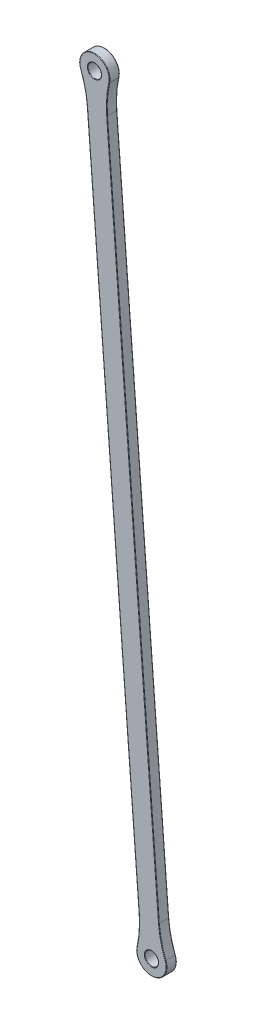
from build123d import *

# Parameters (mm, degrees)
SKETCH1_R           = 2
BOSS_EXTRUDE1_DEPTH = 3
FILLET1_R           = 30
FILLET2_R           = 0.15


with BuildPart() as part:
    # Sketch1 → Boss-Extrude1 (new body)
    with BuildSketch(Plane.XY):
        with BuildLine():
            ThreePointArc((11.251333126, 84.613866333), (14.845502434, 77.013283153), (17.233622255, 85.074536245))
            Line((17.233622255, 85.074536245), (17.491144565, 81.730334956))
            ThreePointArc((17.491144565, 81.730334956), (14.730334956, 78.508855435), (11.508855435, 81.269665044))
            Line((11.508855435, 81.269665044), (11.251333126, 84.613866333))
        make_face()
        with BuildLine():
            Line((0.446357827, 303.075032758), (17.491144565, 81.730334956))
            ThreePointArc((17.491144565, 81.730334956), (14.269665044, 84.491144565), (11.508855435, 81.269665044))
            Line((11.508855435, 81.269665044), (-5.535931303, 302.614362846))
            ThreePointArc((-5.535931303, 302.614362846), (-2.314451782, 299.853553237), (0.446357827, 303.075032758))
        make_face()
        with BuildLine():
            ThreePointArc((-5.535931303, 302.614362846), (-2.775121694, 305.835842367), (0.446357827, 303.075032758))
            Line((0.446357827, 303.075032758), (0.703880137, 299.730831469))
            ThreePointArc((0.703880137, 299.730831469), (-2.890289172, 307.331414649), (-5.278408993, 299.270161557))
            Line((-5.278408993, 299.270161557), (-5.535931303, 302.614362846))
        make_face()
        with BuildLine():
            ThreePointArc((0.446357827, 303.075032758), (-2.314451782, 299.853553237), (-5.535931303, 302.614362846))
            ThreePointArc((-5.535931303, 302.614362846), (-2.775121694, 305.835842367), (0.446357827, 303.075032758))
        make_face()
        with Locations((-2.544786738, 302.844697802)):
            Circle(SKETCH1_R, mode=Mode.SUBTRACT)
        with BuildLine():
            ThreePointArc((11.508855435, 81.269665044), (14.730334956, 78.508855435), (17.491144565, 81.730334956))
            ThreePointArc((17.491144565, 81.730334956), (14.269665044, 84.491144565), (11.508855435, 81.269665044))
        make_face()
        with Locations((14.5, 81.5)):
            Circle(SKETCH1_R, mode=Mode.SUBTRACT)
    extrude(amount=-BOSS_EXTRUDE1_DEPTH)

    # Fillet1
    fillet1_edges = [part.edges().sort_by_distance(p)[0] for p in [
        (17.233622255, 85.074536245, -1.5),
        (11.251333126, 84.613866333, -1.5),
        (-5.278408993, 299.270161557, -1.5),
        (0.703880137, 299.730831469, -1.5),
    ]]
    fillet(fillet1_edges, radius=FILLET1_R)

    # Fillet2
    fillet2_edges = [part.edges().sort_by_distance(p)[0] for p in [
        (2.986462066, 191.942013945, 0),
        (2.986462066, 191.942013945, -3),
        (14.845502434, 77.013283153, 0),
        (14.845502434, 77.013283153, -3),
        (8.968751196, 192.402683857, 0),
        (12.5, 81.5, -3),
        (8.968751196, 192.402683857, -3),
        (-2.890289172, 307.331414649, 0),
        (-2.890289172, 307.331414649, -3),
        (10.74898801, 86.866892878, 0),
        (10.74898801, 86.866892878, -3),
        (-4.544786738, 302.844697802, -3),
        (17.385098862, 87.37791074, 0),
        (17.385098862, 87.37791074, -3),
        (-5.4298856, 296.966787062, 0),
        (-5.4298856, 296.966787062, -3),
        (1.206225252, 297.477804924, 0),
        (1.206225252, 297.477804924, -3),
        (-4.544786738, 302.844697802, 0),
        (12.5, 81.5, 0),
    ]]
    fillet(fillet2_edges, radius=FILLET2_R)


solid = part.part
